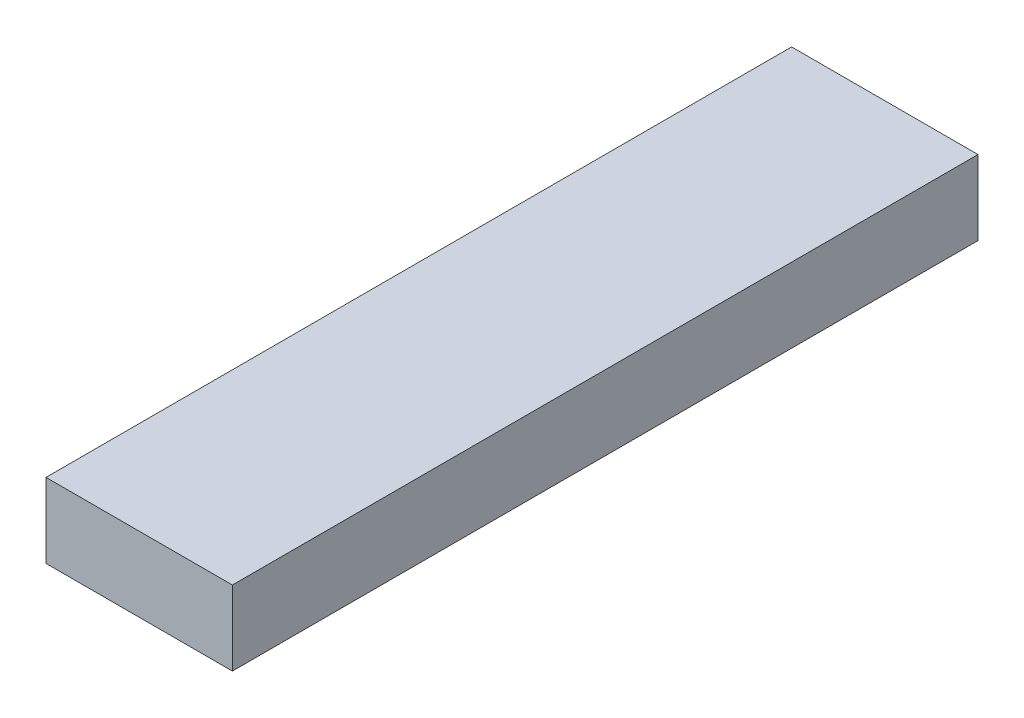
from build123d import *

# Parameters (mm, degrees)
SKETCH_1_W      = 50
SKETCH_1_H      = 200
EXTRUDE_1_DEPTH = 20


with BuildPart() as part:
    # 草图1 → 凸台-拉伸1 (new body)
    with BuildSketch(Plane(origin=(0, 0, 0), x_dir=(1, 0, 0), z_dir=(0, 1, 0))):
        with Locations((25, -100)):
            Rectangle(SKETCH_1_W, SKETCH_1_H)
    extrude(amount=EXTRUDE_1_DEPTH)


solid = part.part
